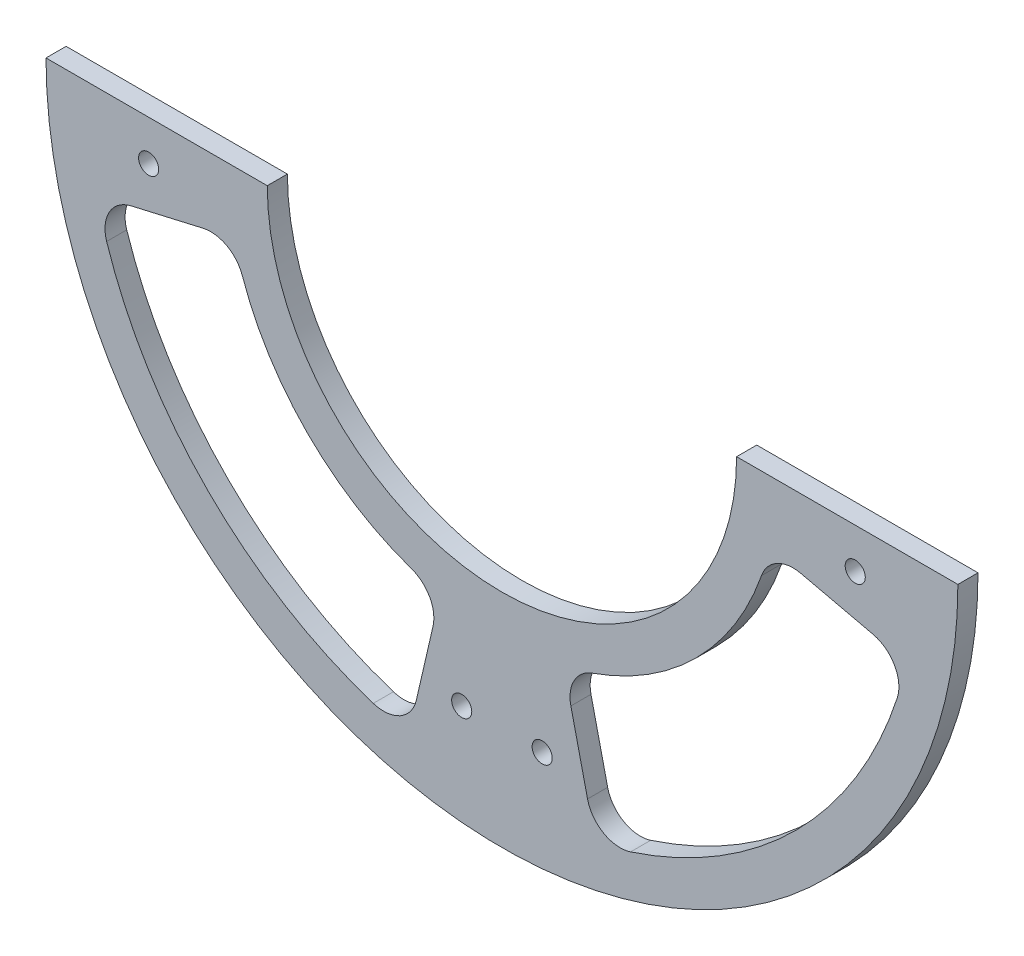
from build123d import *

# Parameters (mm, degrees)
SKETCH_1_R          = 1.5
EXTRUDE_1_DEPTH     = 3
CUT_EXTRUDE_1_DEPTH = 3
FILLET_1_R          = 5


with BuildPart() as part:
    # 草图1 → 凸台-拉伸1 (new body)
    with BuildSketch(Plane.XY):
        with BuildLine():
            Line((-66.898598537, 2.653376251), (-33.898598537, 2.653376251))
            ThreePointArc((-33.898598537, 2.653376251), (1.101401463, -32.346623749), (36.101401463, 2.653376251))
            Line((36.101401463, 2.653376251), (69.101401463, 2.653376251))
            ThreePointArc((69.101401463, 2.653376251), (1.101401463, -65.346623749), (-66.898598537, 2.653376251))
        make_face()
        with Locations((-51.588074716, -3.346623749)):
            Circle(SKETCH_1_R, mode=Mode.SUBTRACT)
        with Locations((-4.898598537, -50.036099928)):
            Circle(SKETCH_1_R, mode=Mode.SUBTRACT)
        with Locations((7.101401463, -50.036099928)):
            Circle(SKETCH_1_R, mode=Mode.SUBTRACT)
        with Locations((53.790877642, -3.346623749)):
            Circle(SKETCH_1_R, mode=Mode.SUBTRACT)
    extrude(amount=EXTRUDE_1_DEPTH)

    # 草图2 → 切除-拉伸1 (cut)
    with BuildSketch(Plane.XY.offset(3)):
        with BuildLine():
            Line((10.319593038, -37.29690465), (15.041105796, -57.759243648))
            ThreePointArc((15.041105796, -57.759243648), (44.942021896, -41.187244183), (61.514021362, -11.286328082))
            Line((61.514021362, -11.286328082), (41.051682364, -6.564815324))
            ThreePointArc((41.051682364, -6.564815324), (30.092779491, -26.338001778), (10.319593038, -37.29690465))
        make_face()
        with BuildLine():
            Line((-8.116790112, -37.29690465), (-12.83830287, -57.759243648))
            ThreePointArc((-12.83830287, -57.759243648), (-42.739218971, -41.187244183), (-59.311218437, -11.286328082))
            Line((-59.311218437, -11.286328082), (-38.848879439, -6.564815324))
            ThreePointArc((-38.848879439, -6.564815324), (-27.889976566, -26.338001778), (-8.116790112, -37.29690465))
        make_face()
    extrude(amount=-CUT_EXTRUDE_1_DEPTH, mode=Mode.SUBTRACT)

    # 圆角1
    fillet_1_edges = [part.edges().sort_by_distance(p)[0] for p in [
        (-38.848879439, -6.564815324, 1.5),
        (-8.116790112, -37.29690465, 1.5),
        (-12.83830287, -57.759243648, 1.5),
        (-59.311218437, -11.286328082, 1.5),
        (10.319593038, -37.29690465, 1.5),
        (41.051682364, -6.564815324, 1.5),
        (61.514021362, -11.286328082, 1.5),
        (15.041105796, -57.759243648, 1.5),
    ]]
    fillet(fillet_1_edges, radius=FILLET_1_R)


solid = part.part
